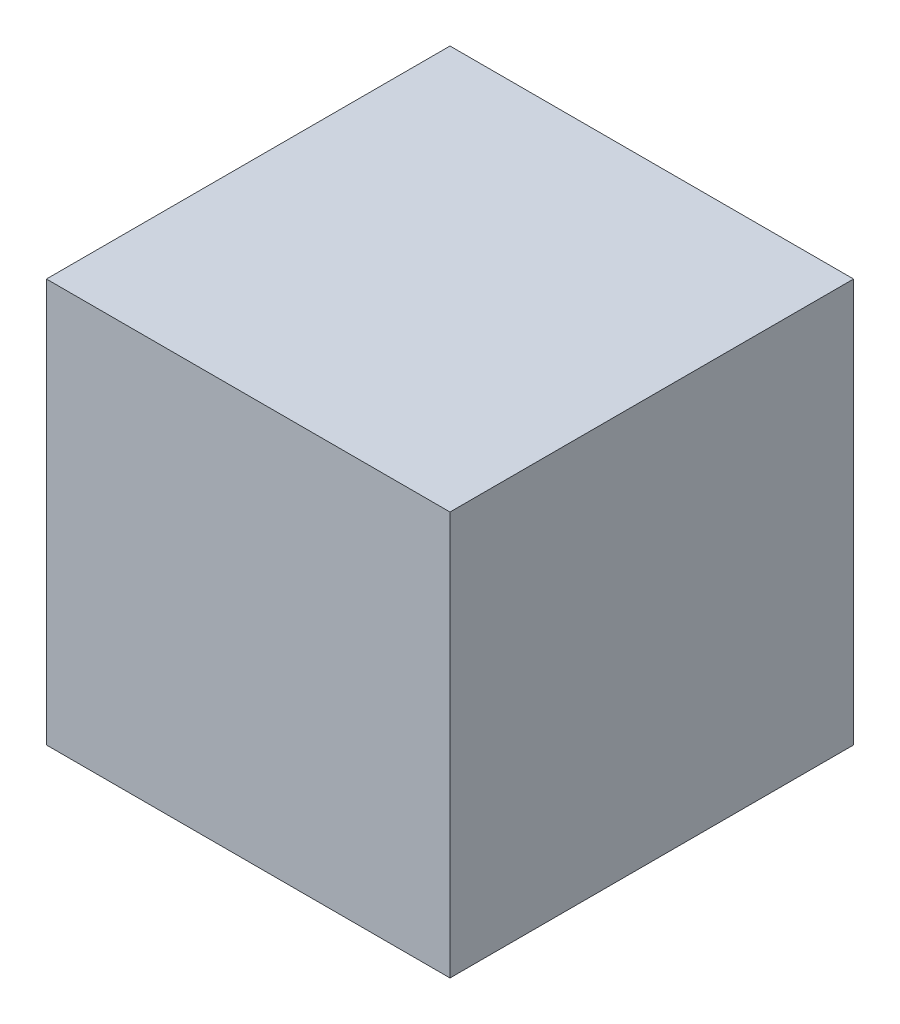
from build123d import *

# Parameters (mm, degrees)
SKETCH2_W           = 31.75
SKETCH2_H           = 31.75
BOSS_EXTRUDE1_DEPTH = 31.75


with BuildPart() as part:
    # Sketch2 → Boss-Extrude1 (new body)
    with BuildSketch(Plane(origin=(0, 0, 0), x_dir=(1, 0, 0), z_dir=(0, 1, 0))):
        Rectangle(SKETCH2_W, SKETCH2_H)
    extrude(amount=BOSS_EXTRUDE1_DEPTH)


solid = part.part
